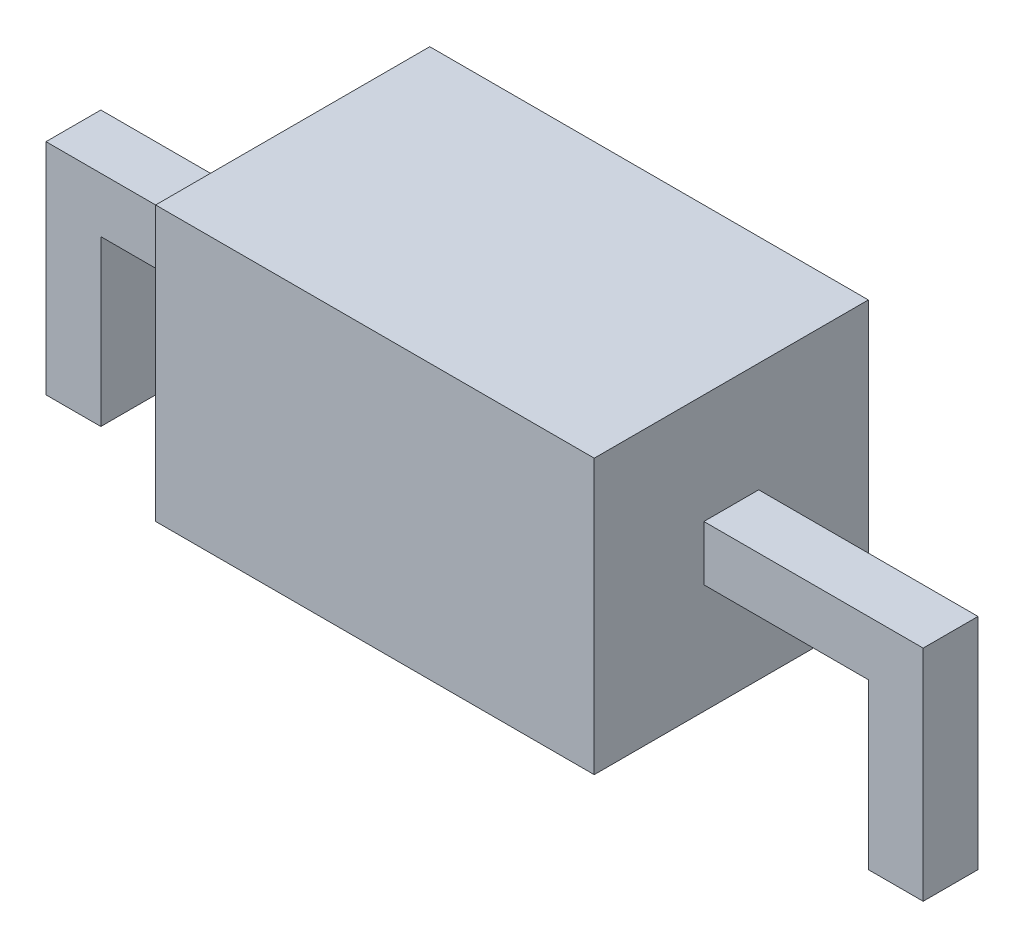
from build123d import *

# Parameters (mm, degrees)
SKETCH3_W                = 4
SKETCH3_H                = 2.5
BOSS_EXTRUDE1_DEPTH      = 2.5
SKETCH6_W                = 1.5
SKETCH6_H                = 0.5
SKETCH6_W_2              = 0.5
SKETCH6_H_2              = 1.5
BOSS_EXTRUDE2_DEPTH      = 0.25
BOSS_EXTRUDE2_DEPTH_BACK = 0.25


with BuildPart() as part:
    # Sketch3 → Boss-Extrude1 (new body)
    with BuildSketch(Plane.XY):
        Rectangle(SKETCH3_W, SKETCH3_H)
    extrude(amount=BOSS_EXTRUDE1_DEPTH)

    # Sketch6 → Boss-Extrude2 (add, two sides)
    with BuildSketch(Plane.XY.offset(1.25)) as boss_extrude2_sk:
        with Locations((2.75, 0)):
            Rectangle(SKETCH6_W, SKETCH6_H)
        with Locations((3.75, 0)):
            Rectangle(SKETCH6_W_2, SKETCH6_H)
        with Locations((3.75, -1)):
            Rectangle(SKETCH6_W_2, SKETCH6_H_2)
        with Locations((-2.75, 0)):
            Rectangle(SKETCH6_W, SKETCH6_H)
        with Locations((-3.75, 0)):
            Rectangle(SKETCH6_W_2, SKETCH6_H)
        with Locations((-3.75, -1)):
            Rectangle(SKETCH6_W_2, SKETCH6_H_2)
    extrude(amount=BOSS_EXTRUDE2_DEPTH)
    extrude(boss_extrude2_sk.sketch, amount=-BOSS_EXTRUDE2_DEPTH_BACK)


solid = part.part
